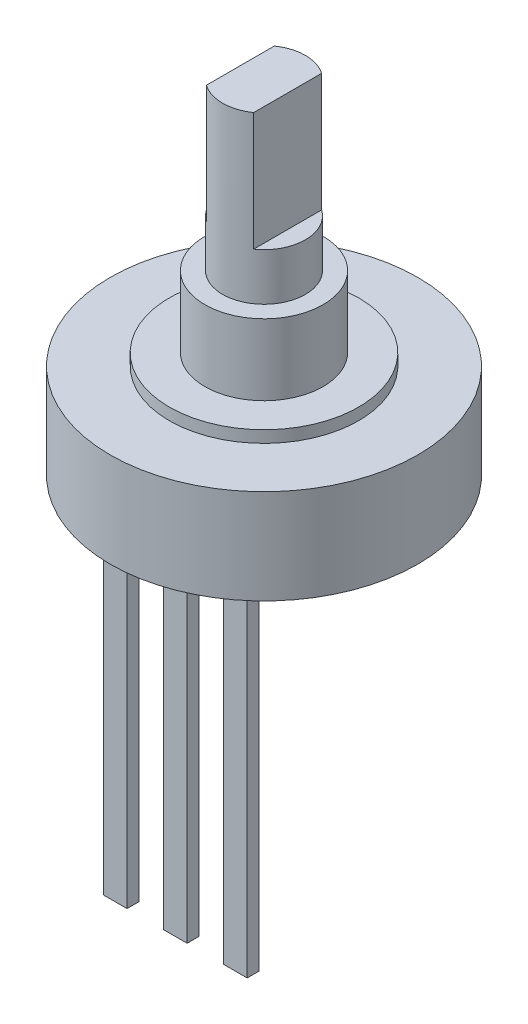
from build123d import *

# Parameters (mm, degrees)
SKETCH1_R          = 1.75
EXTRUDE1_DEPTH     = 7
SKETCH2_W          = 1.290596026
SKETCH2_H          = 4.717350993
SKETCH2_W_2        = 1.446357616
SKETCH2_H_2        = 4.606092715
CUT_EXTRUDE1_DEPTH = 5
SKETCH3_R          = 2.5
EXTRUDE2_DEPTH     = 3
SKETCH4_R          = 4
EXTRUDE3_DEPTH     = 0.5
SKETCH5_R          = 6.5
EXTRUDE4_DEPTH     = 4
SKETCH7_W          = 1
SKETCH7_H          = 0.5
EXTRUDE5_DEPTH     = 15


with BuildPart() as part:
    # Sketch1 → Extrude1 (new body)
    with BuildSketch(Plane(origin=(0, 0, 0), x_dir=(1, 0, 0), z_dir=(0, 1, 0))):
        with Locations(Location((0, 0, 0), (0, 0, 270))):  # turned: the seam where the file's is
            Circle(SKETCH1_R)
    extrude(amount=EXTRUDE1_DEPTH)

    # Sketch2 → Cut-Extrude1 (cut)
    with BuildSketch(Plane(origin=(0, 7, 0), x_dir=(1, 0, 0), z_dir=(0, 1, 0))):
        with Locations((-1.645298013, 0.467284768)):
            Rectangle(SKETCH2_W, SKETCH2_H)
        with Locations((1.723178808, 0.25589404)):
            Rectangle(SKETCH2_W_2, SKETCH2_H_2)
    extrude(amount=-CUT_EXTRUDE1_DEPTH, mode=Mode.SUBTRACT)

    # Sketch3 → Extrude2 (add)
    with BuildSketch(Plane.XZ):
        with Locations(Location((0, 0, 0), (0, 0, 270))):  # turned: the seam where the file's is
            Circle(SKETCH3_R)
    extrude(amount=EXTRUDE2_DEPTH)

    # Sketch4 → Extrude3 (add)
    with BuildSketch(Plane.XZ.offset(3)):
        with Locations(Location((0, 0, 0), (0, 0, 270))):  # turned: the seam where the file's is
            Circle(SKETCH4_R)
    extrude(amount=EXTRUDE3_DEPTH)

    # Sketch5 → Extrude4 (add)
    with BuildSketch(Plane.XZ.offset(3.5)):
        with Locations(Location((0, 0, 0), (0, 0, 270))):  # turned: the seam where the file's is
            Circle(SKETCH5_R)
    extrude(amount=EXTRUDE4_DEPTH)

    # Sketch7 → Extrude5 (add)
    with BuildSketch(Plane.XZ.offset(7.5)):
        with Locations((0, 3.5)):
            Rectangle(SKETCH7_W, SKETCH7_H)
        with Locations((2.54, 3.5)):
            Rectangle(SKETCH7_W, SKETCH7_H)
        with Locations((-2.54, 3.5)):
            Rectangle(SKETCH7_W, SKETCH7_H)
    extrude(amount=EXTRUDE5_DEPTH)


solid = part.part
